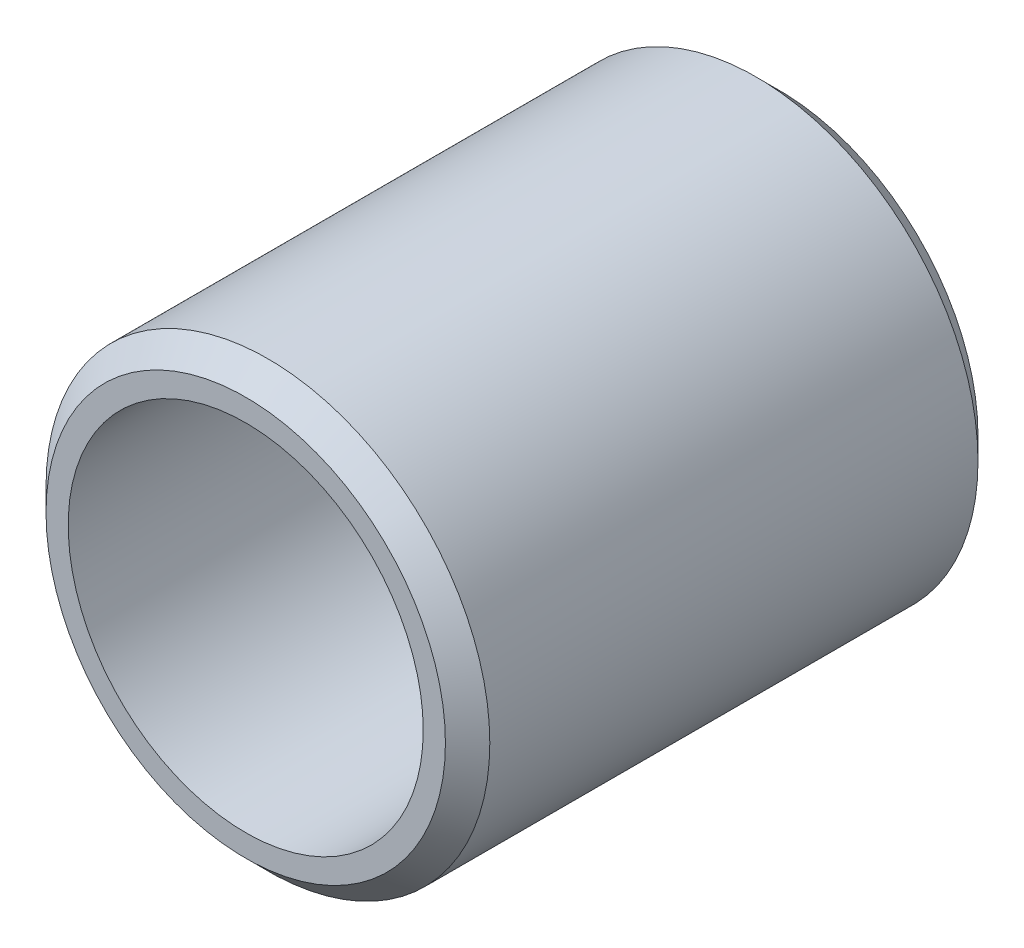
from build123d import *

# Parameters (mm, degrees)
SKETCH_1_R      = 5
SKETCH_1_R_2    = 4
EXTRUDE_1_DEPTH = 12
CHAMFER_1_SIZE  = 0.5


with BuildPart() as part:
    # Эскиз1 → Бобышка-Вытянуть1 (new body)
    with BuildSketch(Plane.XY):
        Circle(SKETCH_1_R)
        Circle(SKETCH_1_R_2, mode=Mode.SUBTRACT)
    extrude(amount=EXTRUDE_1_DEPTH)

    # Фаска1
    chamfer_1_edges = [part.edges().sort_by_distance(p)[0] for p in [
        (-5, 0, 0),
        (-5, 0, 12),
    ]]
    chamfer(chamfer_1_edges, length=CHAMFER_1_SIZE)


solid = part.part
